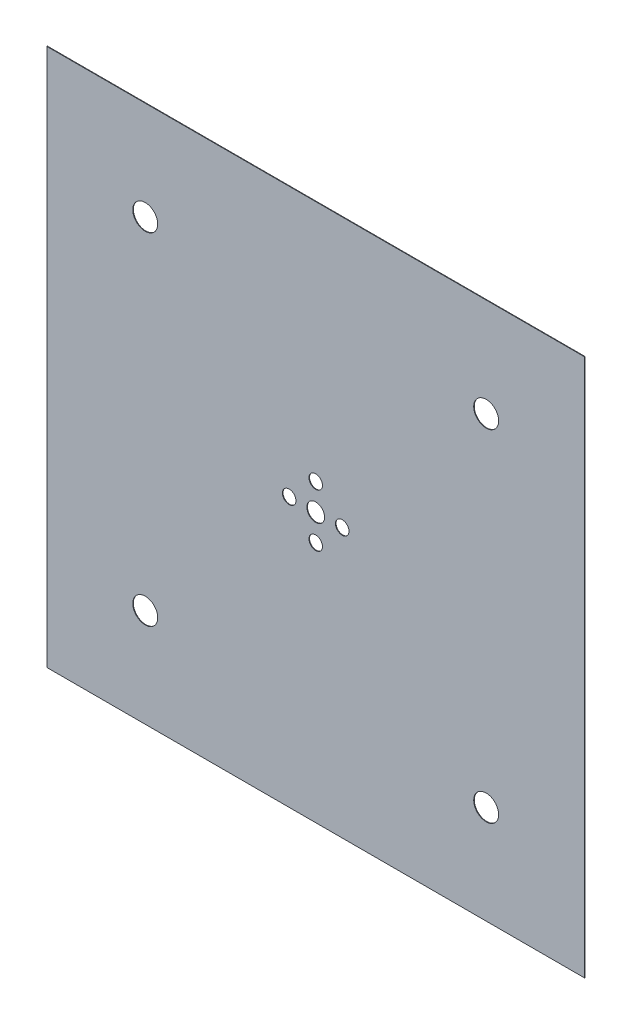
from build123d import *

# Parameters (mm, degrees)
SKETCH1_W           = 2840
SKETCH1_H           = 2840
SKETCH1_R           = 46.75
SKETCH1_R_2         = 35.6375
SKETCH1_R_3         = 65.8
BOSS_EXTRUDE1_DEPTH = 3


with BuildPart() as part:
    # Sketch1 → Boss-Extrude1 (new body)
    with BuildSketch(Plane.XY):
        Rectangle(SKETCH1_W, SKETCH1_H)
        Circle(SKETCH1_R, mode=Mode.SUBTRACT)
        with Locations((0, 140)):
            Circle(SKETCH1_R_2, mode=Mode.SUBTRACT)
        with Locations((-900, 900)):
            Circle(SKETCH1_R_3, mode=Mode.SUBTRACT)
        with Locations((900, -900)):
            Circle(SKETCH1_R_3, mode=Mode.SUBTRACT)
        with Locations((0, -140)):
            Circle(SKETCH1_R_2, mode=Mode.SUBTRACT)
        with Locations((900, 900)):
            Circle(SKETCH1_R_3, mode=Mode.SUBTRACT)
        with Locations((-900, -900)):
            Circle(SKETCH1_R_3, mode=Mode.SUBTRACT)
        with Locations((140, 0)):
            Circle(SKETCH1_R_2, mode=Mode.SUBTRACT)
        with Locations((-140, 0)):
            Circle(SKETCH1_R_2, mode=Mode.SUBTRACT)
    extrude(amount=BOSS_EXTRUDE1_DEPTH)


solid = part.part
